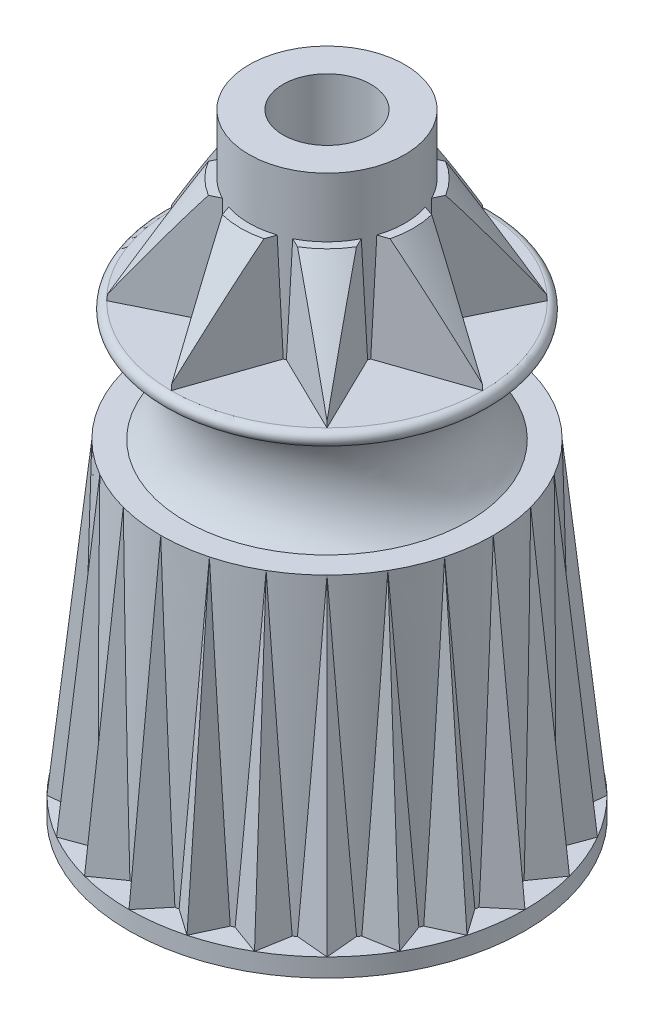
from build123d import *
from build123d.topology import SkipClean

# Parameters (mm, degrees)
SKETCH1_R           = 8.89
BOSS_EXTRUDE1_DEPTH = 0.8128
BOSS_EXTRUDE1_TAPER = 1
SKETCH2_R           = 7.4549
SKETCH3_R           = 7.8105
CIRPATTERN1_COUNT   = 24
SKETCH8_R           = 3.4925
BOSS_EXTRUDE2_DEPTH = 7.4168
SKETCH9_R           = 1.9685
CUT_EXTRUDE1_DEPTH  = 28.4320001
BOSS_EXTRUDE3_DEPTH = 4.7498
BOSS_EXTRUDE3_TAPER = 2
CIRPATTERN2_COUNT   = 8
FILLET1_R           = 0.762
RIB1_REACH          = 27.654
SKETCH13_WALLS_W    = 1.016
SKETCH13_WALLS_H    = 57.352278555
RIB1_DRAFT_ANGLE    = 1
FILLET2_R           = 0.508


with BuildPart() as part:
    # Sketch1 → Boss-Extrude1 (new body)
    with BuildSketch(Plane(origin=(0, 0, 0), x_dir=(1, 0, 0), z_dir=(0, 1, 0))):
        Circle(SKETCH1_R)
    extrude(amount=BOSS_EXTRUDE1_DEPTH, taper=BOSS_EXTRUDE1_TAPER)

    # Sketch2 → Loft1 section 0
    with BuildSketch(Plane(origin=(0, 14.6304, 0), x_dir=(1, 0, 0), z_dir=(0, 1, 0))):
        Circle(SKETCH2_R)
    # Sketch3 → Loft1 section 1
    with BuildSketch(Plane(origin=(0, 0.8128, 0), x_dir=(1, 0, 0), z_dir=(0, 1, 0))):
        Circle(SKETCH3_R)
    loft()

    # Sweep1: sweep along a path in Sketch4
    with SkipClean():  # keep this step's faces unmerged: merging them makes the solid invalid here
        with BuildLine(Plane(origin=(0, 0, 0), x_dir=(0, 0, -1), z_dir=(1, 0, 0))) as sweep1_path:
            Line((-8.875812523, 0.8128), (-7.4549, 14.6304))
        # Sketch5 → Sweep1 (sweep)
        with BuildSketch(Plane(origin=(0, 0.8128, 8.875812523), x_dir=(1, 0, 0), z_dir=(0, 0.994754201, -0.102294082))):
            Polygon((0, 0), (1.278787838, 1.524), (-1.278787838, 1.524), align=None)
        sweep1 = sweep(path=sweep1_path.line)

    # CirPattern1: Sweep1 ×24 about axis
    cirpattern1_axis = Axis((0, 0, 0), (0, 1, 0))
    for i in range(1, CIRPATTERN1_COUNT):
        add(sweep1.rotate(cirpattern1_axis, i * 360 / CIRPATTERN1_COUNT))

    # Sketch7 → Revolve1 (revolve)
    with BuildSketch(Plane(origin=(0, 0, 0), x_dir=(0, 0, -1), z_dir=(1, 0, 0))):
        with BuildLine():
            Line((0, 20.0152), (6.985, 20.0152))
            ThreePointArc((6.985, 20.0152), (7.3025, 19.6977), (6.985, 19.3802))
            Line((6.985, 19.3802), (6.35, 19.3802))
            ThreePointArc((6.35, 19.3802), (5.3467, 17.0053), (6.35, 14.6304))
            Line((6.35, 14.6304), (0, 14.6304))
            Line((0, 14.6304), (0, 20.0152))
        make_face()
    revolve(axis=Axis((0, 14.6304, 0), (0, 1, 0)))

    # Sketch8 → Boss-Extrude2 (add)
    with BuildSketch(Plane(origin=(0, 20.0152, 0), x_dir=(1, 0, 0), z_dir=(0, 1, 0))):
        with Locations(Location((0, 0, 0), (0, 0, 270))):  # turned: the seam where the file's is
            Circle(SKETCH8_R)
    extrude(amount=BOSS_EXTRUDE2_DEPTH)

    # Sketch9 → Cut-Extrude1 (cut, through all)
    with BuildSketch(Plane(origin=(0, 27.432, 0), x_dir=(1, 0, 0), z_dir=(0, 1, 0))):
        with Locations(Location((0, 0, 0), (0, 0, 270))):  # turned: the seam where the file's is
            Circle(SKETCH9_R)
    extrude(amount=-CUT_EXTRUDE1_DEPTH, mode=Mode.SUBTRACT)

    # Sketch10 → Boss-Extrude3 (add)
    with BuildSketch(Plane(origin=(0, 20.0152, 0), x_dir=(1, 0, 0), z_dir=(0, 1, 0))):
        Polygon((0, -6.985), (1.56635116, -2.435985924), (-1.56635116, -2.435985924), align=None)
    boss_extrude3 = extrude(amount=BOSS_EXTRUDE3_DEPTH, taper=BOSS_EXTRUDE3_TAPER)

    # CirPattern2: Boss-Extrude3 ×8 about axis
    cirpattern2_axis = Axis((0, 0, 0), (0, 1, 0))
    for i in range(1, CIRPATTERN2_COUNT):
        add(boss_extrude3.rotate(cirpattern2_axis, i * 360 / CIRPATTERN2_COUNT))

    # Sketch11 → Cut-Revolve1 (revolve, cut)
    with BuildSketch(Plane(origin=(0, 0, 0), x_dir=(0, 0, -1), z_dir=(1, 0, 0)), mode=Mode.PRIVATE) as cut_revolve1_sk:
        Polygon((3.4925, 24.765), (3.4925, 27.432), (7.465911085, 27.432), (7.465911085, 20.267751363), (6.957911085, 20.267751363), (3.8735, 24.765), align=None)
    revolve(cut_revolve1_sk.sketch.rotate(Axis((0, 64.742281733, 0), (0, -1, 0)), 18.131332636), axis=Axis((0, 64.742281733, 0), (0, -1, 0)), mode=Mode.SUBTRACT)  # turned: the seam where the file's is

    # Sketch12 → Cut-Revolve2 (revolve, cut)
    with BuildSketch(Plane(origin=(0, 0, 0), x_dir=(0, 0, -1), z_dir=(1, 0, 0))):
        with BuildLine():
            Line((2.921, 0), (3.194108928, 15.6464))
            Line((3.194108928, 15.6464), (4.549542973, 15.6464))
            ThreePointArc((4.549542973, 15.6464), (4.990447661, 14.708323353), (5.641733851, 13.901966707))
            Line((5.641733851, 13.901966707), (5.889715871, 13.901966707))
            Line((5.889715871, 13.901966707), (6.270518716, 2.9972))
            Line((6.270518716, 2.9972), (6.448427093, 2.9972))
            Line((6.448427093, 2.9972), (6.491002495, 1.778))
            Line((6.491002495, 1.778), (6.668910872, 1.778))
            Line((6.668910872, 1.778), (6.731, 0))
            Line((6.731, 0), (6.731, -2.54))
            Line((6.731, -2.54), (2.921, -2.54))
            Line((2.921, -2.54), (2.921, 0))
        make_face()
    revolve(axis=Axis((0, 0, 0), (0, 1, 0)), mode=Mode.SUBTRACT)

    # Fillet1
    fillet1_edges = [part.edges().sort_by_distance(p)[0] for p in [
        (0, 0, 6.731),
    ]]
    fillet(fillet1_edges, radius=FILLET1_R)

    # Sketch13 walls → Rib1 (add, up to next)
    with BuildSketch(Plane.XZ.offset(-1.778), mode=Mode.PRIVATE) as rib1_sk1:
        with Locations((0, -4.468863318)):
            Rectangle(SKETCH13_WALLS_W, SKETCH13_WALLS_H)
    rib1_tool1 = extrude(rib1_sk1.sketch, amount=-RIB1_REACH, mode=Mode.PRIVATE) - part.part
    add(rib1_tool1.solids().sort_by_distance((0, 1.778, -4.468863317))[0])
    # Sketch13 walls → Rib1 (add, up to next)
    with BuildSketch(Plane.XZ.offset(-1.778), mode=Mode.PRIVATE) as rib1_sk2:
        with Locations((0, 4.468863318)):
            Rectangle(SKETCH13_WALLS_W, SKETCH13_WALLS_H)
    rib1_tool2 = extrude(rib1_sk2.sketch, amount=-RIB1_REACH, mode=Mode.PRIVATE) - part.part
    add(rib1_tool2.solids().sort_by_distance((0, 1.778, 4.468863317))[0])

    # Rib1 draft
    rib1_draft_faces = [part.faces().sort_by_distance(p)[0] for p in [
        (0.508, 2.032, -4.468863318),
        (-0.508, 2.032, -4.468863318),
        (0.508, 2.032, 4.468863318),
        (-0.508, 2.032, 4.468863318),
    ]]
    draft(rib1_draft_faces, Plane(origin=(0, 1.778, -4.468863317), x_dir=(1, 0, 0), z_dir=(0, -1, 0)), RIB1_DRAFT_ANGLE)

    # Fillet2
    fillet2_edges = [part.edges().sort_by_distance(p)[0] for p in [
        (0.508, 1.778, 4.689545246),
        (-0.508, 1.778, 4.689545246),
        (-0.508, 1.778, -4.689545246),
        (0.508, 1.778, -4.689545246),
    ]]
    fillet(fillet2_edges, radius=FILLET2_R)


solid = part.part
